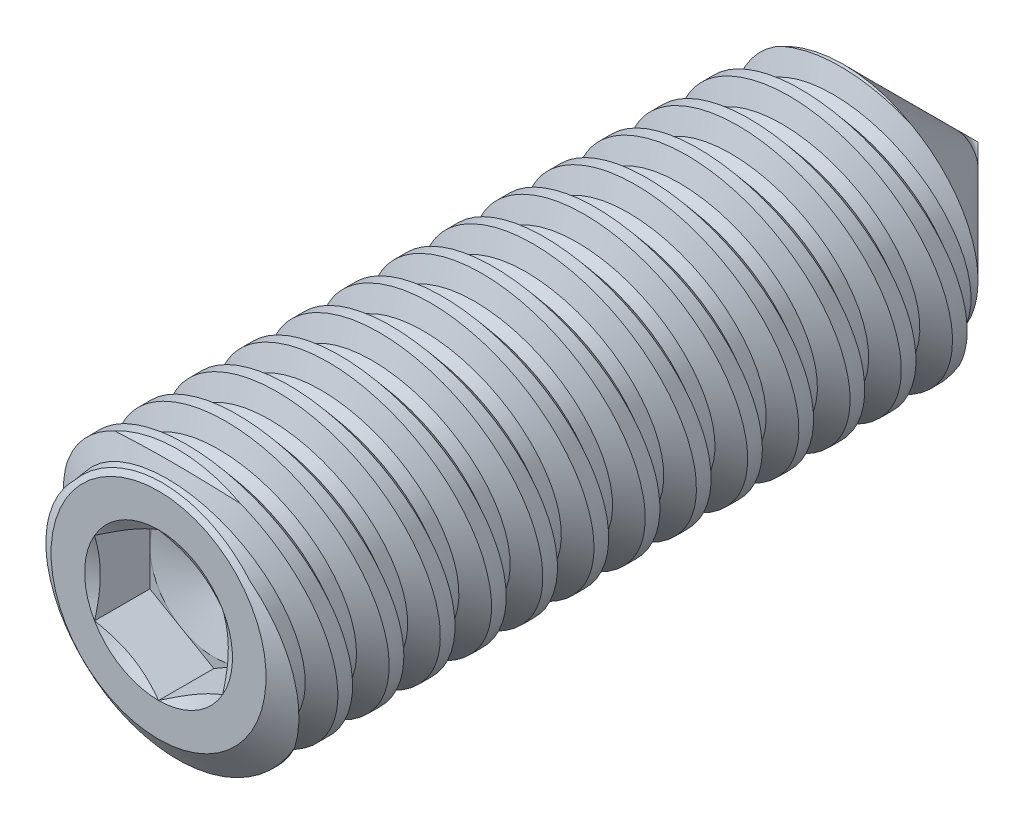
from build123d import *

# Parameters (mm, degrees)
LPATTERN1_COUNT      = 14
LPATTERN1_PITCH      = 0.79375
LPATTERN1_COUNT_DIR2 = 2
LPATTERN1_PITCH_DIR2 = 0.79375
CUT_EXTRUDE10_DEPTH  = 0.85725


with BuildPart() as part:
    # Sketch22 → Revolve1 (revolve)
    with BuildSketch(Plane(origin=(0, 0, 0), x_dir=(0, 0, -1), z_dir=(1, 0, 0))):
        Polygon((-6.35, 0), (-6.35, 1.66624), (-6.058321548, 2.0828), (4.2672, 2.0828), (6.35, 0), align=None)
    revolve(axis=Axis((0, 0, -6.858525863), (0, 0, 1)))

    # Sketch6 → Cut-Revolve8 (revolve, cut)
    with BuildSketch(Plane(origin=(0, 0, 0), x_dir=(0, 0, -1), z_dir=(1, 0, 0))):
        Polygon((4.103955739, 1.762908932), (3.909025531, 1.725765218), (3.584944272, 2.101371857), (4.2672, 2.231374854), align=None)
    cut_revolve8 = revolve(axis=Axis((0, 0.162231854, -5.190264706), (0, -0.18718091792156344, 0.9823254572523513)), mode=Mode.SUBTRACT)

    # LPattern1: Cut-Revolve8 14 × 2
    with Locations(*[Vector(0, 0, 1) * (i * LPATTERN1_PITCH) + Vector(0, 0, -1) * (j * LPATTERN1_PITCH_DIR2) for i in range(LPATTERN1_COUNT) for j in range(LPATTERN1_COUNT_DIR2) if (i, j) != (0, 0)]):
        add(cut_revolve8, mode=Mode.SUBTRACT)

    # Sketch23 → Cut-Extrude10 (cut)
    with BuildSketch(Plane.XY.offset(6.35)):
        Polygon((0, 1.14567944), (-0.9921875, 0.57283972), (-0.9921875, -0.57283972), (0, -1.14567944), (0.9921875, -0.57283972), (0.9921875, 0.57283972), align=None)
    extrude(amount=-CUT_EXTRUDE10_DEPTH, mode=Mode.SUBTRACT)

    # Cut-Extrude11 cone 1 section (through the dimple's axis) → Cut-Extrude11 (revolve, cut)
    with BuildSketch(Plane(origin=(0, 0, 6.35), x_dir=(0, -1, 0), z_dir=(1, 0, 0))):
        Polygon((0, 0), (1.14567944, 0), (0, 0.661458333), align=None)
    revolve(axis=Axis((0, 0, 6.35), (0, 0, -1)), mode=Mode.SUBTRACT)

    # Cut-Extrude12 cone 1 section (through the dimple's axis) → Cut-Extrude12 (revolve, cut)
    with BuildSketch(Plane(origin=(0, 0, 5.49275), x_dir=(0, -1, 0), z_dir=(1, 0, 0))):
        Polygon((0, 0), (0.9921875, 0), (0, 0.265855839), align=None)
    revolve(axis=Axis((0, 0, 5.49275), (0, 0, -1)), mode=Mode.SUBTRACT)


solid = part.part
